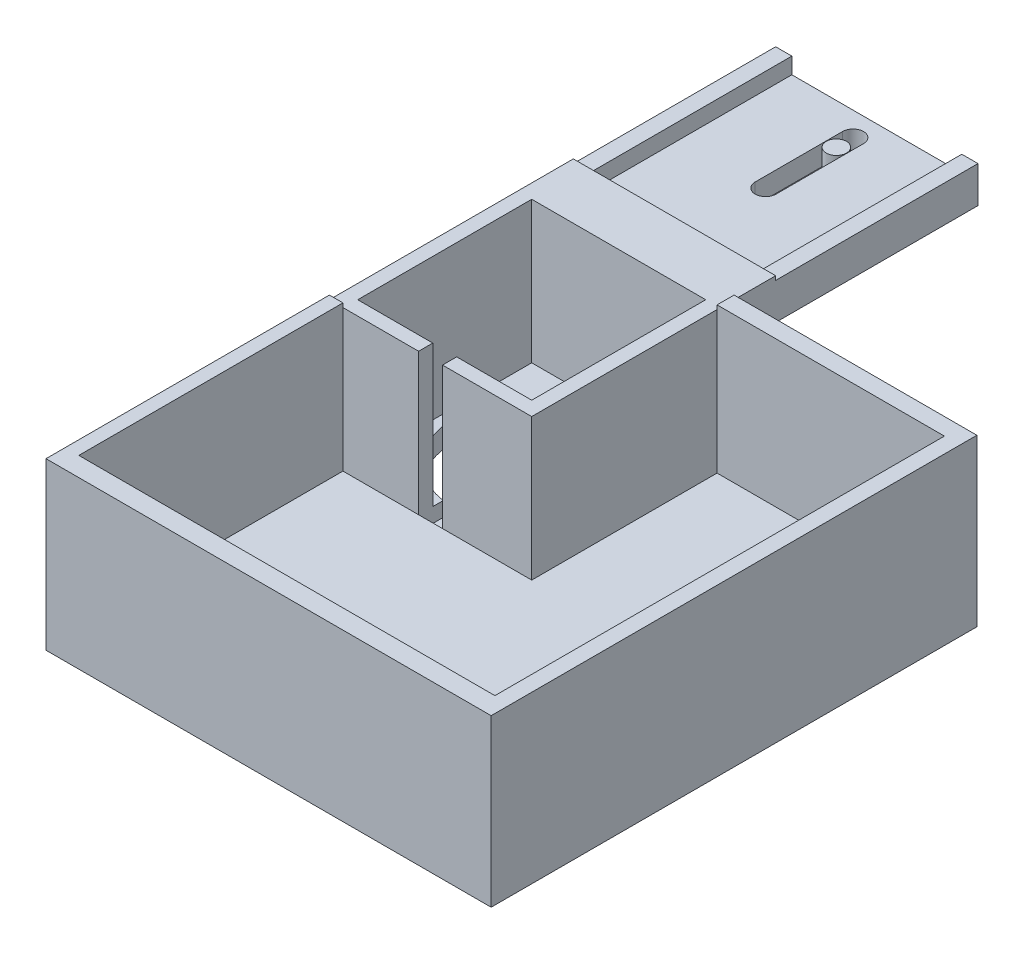
from build123d import *

# Parameters (mm, degrees)
CROQUIS1_W                   = 50
CROQUIS1_H                   = 50
SALIENTE_EXTRUIR1_DEPTH      = 40
CROQUIS3_W                   = 43
CROQUIS3_H                   = 43
CORTAR_EXTRUIR3_DEPTH        = 35
CROQUIS5_W                   = 10.279142756
CROQUIS5_H                   = 10
SALIENTE_EXTRUIR2_DEPTH      = 25
SALIENTE_EXTRUIR2_DEPTH_BACK = 25
CROQUIS6_W                   = 50
CROQUIS6_H                   = 5
SALIENTE_EXTRUIR3_DEPTH      = 25
SALIENTE_EXTRUIR3_DEPTH_BACK = 25
CROQUIS7_W                   = 4
CROQUIS7_H                   = 50
SALIENTE_EXTRUIR4_DEPTH      = 4
CROQUIS8_R                   = 2.5
CORTAR_EXTRUIR5_DEPTH        = 4
CORTAR_EXTRUIR5_DEPTH_BACK   = 24
CROQUIS12_W                  = 5.911432894
CROQUIS12_H                  = 39.020469491
CORTAR_EXTRUIR7_DEPTH        = 10
CROQUIS13_R                  = 19.144660632
CORTAR_EXTRUIR8_DEPTH        = 10
SALIENTE_EXTRUIR6_DEPTH      = 41
CORTAR_EXTRUIR9_DEPTH        = 36
CROQUIS16_W                  = 9.2
CROQUIS16_H                  = 12
CORTAR_EXTRUIR10_DEPTH       = 36


with BuildPart() as part:
    # Croquis1 → Saliente-Extruir1 (new body)
    with BuildSketch(Plane(origin=(0, 0, 0), x_dir=(1, 0, 0), z_dir=(0, 1, 0))):
        Rectangle(CROQUIS1_W, CROQUIS1_H)
    extrude(amount=SALIENTE_EXTRUIR1_DEPTH)

    # Croquis3 → Cortar-Extruir3 (cut)
    with BuildSketch(Plane(origin=(0, 40, 0), x_dir=(1, 0, 0), z_dir=(0, 1, 0))):
        Rectangle(CROQUIS3_W, CROQUIS3_H)
    extrude(amount=-CORTAR_EXTRUIR3_DEPTH, mode=Mode.SUBTRACT)

    # Croquis5 → Saliente-Extruir2 (add, two sides)
    with BuildSketch(Plane(origin=(0, 0, 0), x_dir=(0, 0, -1), z_dir=(1, 0, 0))) as saliente_extruir2_sk:
        with Locations((30.139571378, 35)):
            Rectangle(CROQUIS5_W, CROQUIS5_H)
    extrude(amount=SALIENTE_EXTRUIR2_DEPTH)
    extrude(saliente_extruir2_sk.sketch, amount=-SALIENTE_EXTRUIR2_DEPTH_BACK)

    # Croquis6 → Saliente-Extruir3 (add, two sides)
    with BuildSketch(Plane(origin=(0, 0, 0), x_dir=(0, 0, -1), z_dir=(1, 0, 0))) as saliente_extruir3_sk:
        with Locations((60.279142756, 32.5)):
            Rectangle(CROQUIS6_W, CROQUIS6_H)
    extrude(amount=SALIENTE_EXTRUIR3_DEPTH)
    extrude(saliente_extruir3_sk.sketch, amount=-SALIENTE_EXTRUIR3_DEPTH_BACK)

    # Croquis7 → Saliente-Extruir4 (add)
    with BuildSketch(Plane(origin=(0, 35, 0), x_dir=(1, 0, 0), z_dir=(0, 1, 0))):
        with Locations((23, 60.279142756)):
            Rectangle(CROQUIS7_W, CROQUIS7_H)
        with Locations((-23, 60.279142756)):
            Rectangle(CROQUIS7_W, CROQUIS7_H)
    extrude(amount=SALIENTE_EXTRUIR4_DEPTH)

    # Croquis8 → Cortar-Extruir5 (cut, two sides)
    with BuildSketch(Plane(origin=(0, 35, 0), x_dir=(1, 0, 0), z_dir=(0, 1, 0))) as cortar_extruir5_sk:
        with BuildLine():
            Line((2.594795299, 79.406752636), (2.594795299, 57.800113609))
            ThreePointArc((2.594795299, 57.800113609), (0, 55.20531831), (-2.594795299, 57.800113609))
            Line((-2.594795299, 57.800113609), (-2.594795299, 79.406752636))
            ThreePointArc((-2.594795299, 79.406752636), (0, 82.001547935), (2.594795299, 79.406752636))
        make_face()
        with Locations((0, 75.279142756)):
            Circle(CROQUIS8_R, mode=Mode.SUBTRACT)
    extrude(amount=CORTAR_EXTRUIR5_DEPTH, mode=Mode.SUBTRACT)
    extrude(cortar_extruir5_sk.sketch, amount=-CORTAR_EXTRUIR5_DEPTH_BACK, mode=Mode.SUBTRACT)

    # Croquis12 → Cortar-Extruir7 (cut)
    with BuildSketch(Plane.XY.offset(25)):
        with Locations((0, 20.897214315)):
            Rectangle(CROQUIS12_W, CROQUIS12_H)
    extrude(amount=-CORTAR_EXTRUIR7_DEPTH, mode=Mode.SUBTRACT)

    # Croquis13 → Cortar-Extruir8 (cut)
    with BuildSketch(Plane.XZ):
        Circle(CROQUIS13_R)
    extrude(amount=-CORTAR_EXTRUIR8_DEPTH, mode=Mode.SUBTRACT)

    # Croquis14 → Saliente-Extruir6 (add)
    with BuildSketch(Plane(origin=(0, 0, 0), x_dir=(1, 0, 0), z_dir=(0, 1, 0))):
        Polygon((25, -25), (25, 25), (85, 25), (85, -25), (85, -95.028675022), (-25, -95.028675022), (-25, -25), align=None)
    extrude(amount=SALIENTE_EXTRUIR6_DEPTH)

    # Croquis15 → Cortar-Extruir9 (cut)
    with BuildSketch(Plane(origin=(0, 41, 0), x_dir=(1, 0, 0), z_dir=(0, 1, 0))):
        Polygon((25, 20.799862751), (81.174684786, 20.799862751), (81.174684786, -90.273805278), (-21.646948679, -90.273805278), (-21.646948679, -25), (25, -25), align=None)
    extrude(amount=-CORTAR_EXTRUIR9_DEPTH, mode=Mode.SUBTRACT)

    # Croquis16 → Cortar-Extruir10 (cut)
    with BuildSketch(Plane.ZY.offset(25)):
        with Locations((85.263986229, 11.614610625)):
            Rectangle(CROQUIS16_W, CROQUIS16_H)
    extrude(amount=-CORTAR_EXTRUIR10_DEPTH, mode=Mode.SUBTRACT)


solid = part.part
